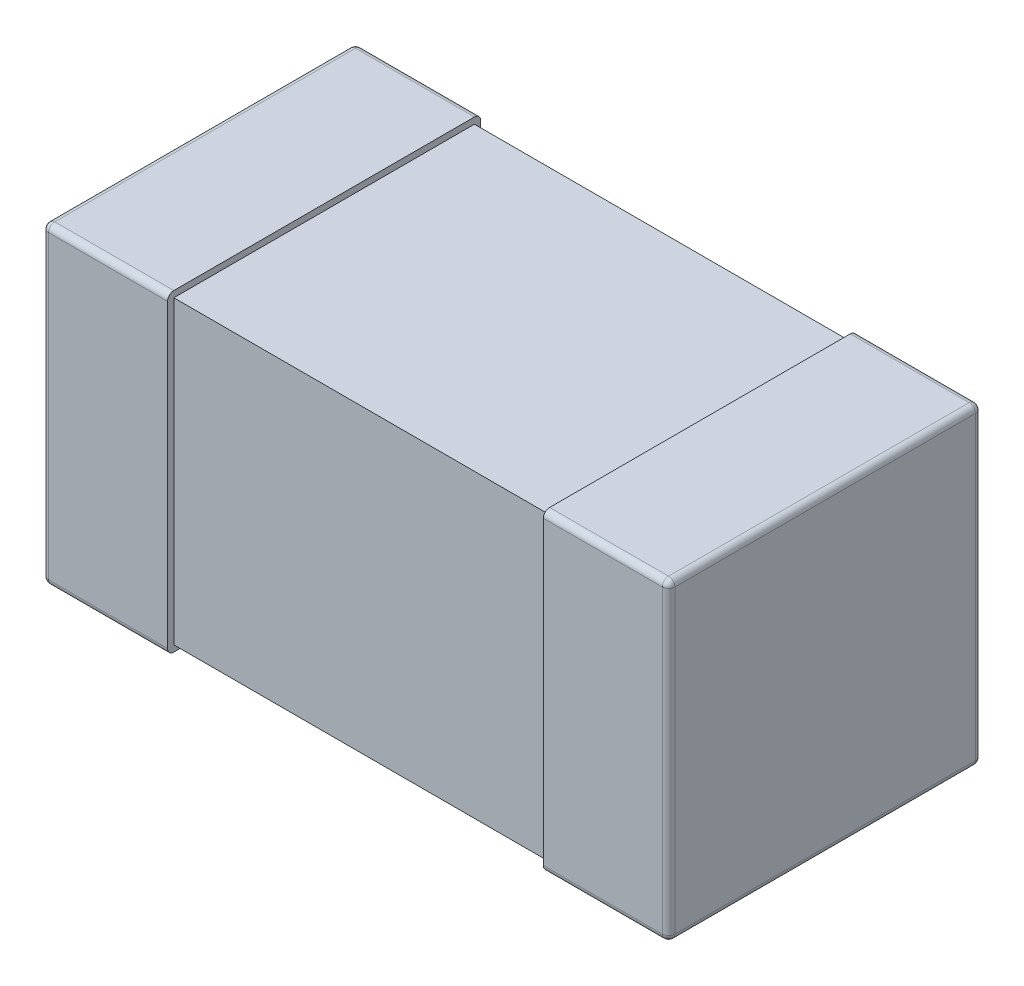
from build123d import *

# Parameters (mm, degrees)
SKETCH1_W            = 0.2
SKETCH1_H            = 0.5
THICKNESS_DEPTH      = 0.25
FILLET1_R            = 0.01
SKETCH2_W            = 0.48
SKETCH2_H            = 0.48
BOSS_EXTRUDE2_DEPTH  = 0.3
FILLET1_OF_MIRROR3_R = 0.01


with BuildPart() as part:
    # Sketch1 → THICKNESS (new body, symmetric)
    with BuildSketch(Plane(origin=(0, 0, 0), x_dir=(1, 0, 0), z_dir=(0, 1, 0))):
        with Locations((-0.4, 0)):
            Rectangle(SKETCH1_W, SKETCH1_H)
    thickness = extrude(amount=THICKNESS_DEPTH, both=True)

    # Fillet1
    fillet1_edges = [part.edges().sort_by_distance(p)[0] for p in [
        (-0.4, 0.25, -0.25),
        (-0.5, 0.25, 0),
        (-0.4, -0.25, -0.25),
        (-0.4, -0.25, 0.25),
        (-0.5, -0.25, 0),
        (-0.4, 0.25, 0.25),
        (-0.5, 0, -0.25),
        (-0.5, 0, 0.25),
    ]]
    fillet(fillet1_edges, radius=FILLET1_R)

    # Sketch2 → Boss-Extrude2 (add)
    with BuildSketch(Plane(origin=(0, 0, 0), x_dir=(0, 0, -1), z_dir=(1, 0, 0))):
        Rectangle(SKETCH2_W, SKETCH2_H)
    boss_extrude2 = extrude(amount=-BOSS_EXTRUDE2_DEPTH)

    # Mirror3: THICKNESS, Boss-Extrude2 across plane
    add(thickness.mirror(Plane(origin=(0, 0, 0), x_dir=(0, 0, 1), z_dir=(1, 0, 0))))
    add(boss_extrude2.mirror(Plane(origin=(0, 0, 0), x_dir=(0, 0, 1), z_dir=(1, 0, 0))))

    # Fillet1 of Mirror3
    fillet1_of_mirror3_edges = [part.edges().sort_by_distance(p)[0] for p in [
        (0.4, 0.25, -0.25),
        (0.5, 0.25, 0),
        (0.4, -0.25, -0.25),
        (0.4, -0.25, 0.25),
        (0.5, -0.25, 0),
        (0.4, 0.25, 0.25),
        (0.5, 0, -0.25),
        (0.5, 0, 0.25),
    ]]
    fillet(fillet1_of_mirror3_edges, radius=FILLET1_OF_MIRROR3_R)


solid = part.part
